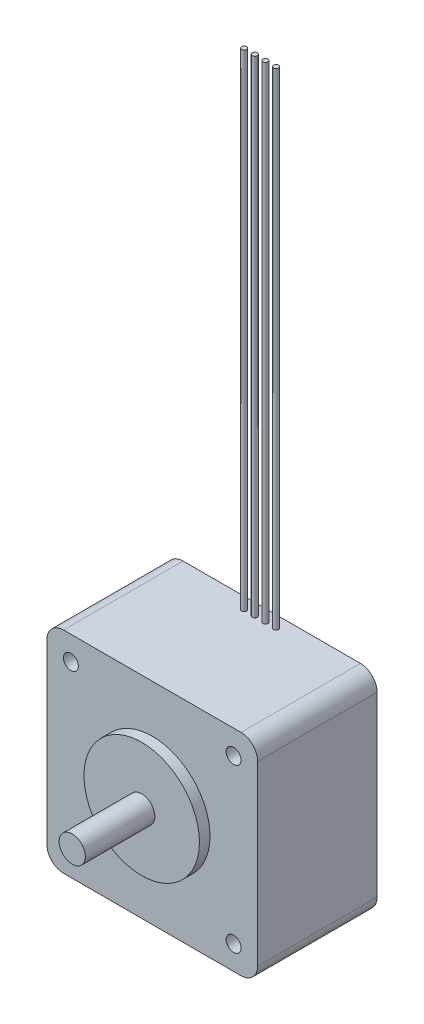
from build123d import *

# Parameters (mm, degrees)
SKETCH1_W           = 40.132
SKETCH1_H           = 40.132
BOSS_EXTRUDE1_DEPTH = 22.7584
SKETCH2_W           = 0.4826
SKETCH2_H           = 92.619583511
SKETCH3_W           = 0.4826
SKETCH3_H           = 92.619583511
SKETCH4_W           = 0.4826
SKETCH4_H           = 92.619583511
SKETCH5_W           = 0.4826
SKETCH5_H           = 92.619583511
HOLE1_D             = 2.8448
HOLE1_DEPTH         = 21.9964
HOLE2_D             = 2.8448
HOLE2_DEPTH         = 21.9964
HOLE3_D             = 2.8448
HOLE3_DEPTH         = 21.9964
HOLE4_D             = 2.8448
HOLE4_DEPTH         = 21.9964
FILLET1_R           = 3.175
FILLET2_R           = 3.175
FILLET3_R           = 3.175
FILLET4_R           = 3.175


with BuildPart() as part:
    # Sketch1 → Boss-Extrude1 (new body)
    with BuildSketch(Plane.XY.offset(22.7584)):
        Rectangle(SKETCH1_W, SKETCH1_H)
    extrude(amount=-BOSS_EXTRUDE1_DEPTH)

    # Sketch2 → Revolve1 (revolve)
    with BuildSketch(Plane(origin=(0, 0, 2.2098), x_dir=(-1, 0, 0), z_dir=(0, 0, -1))):
        with Locations((2.8067, 66.375791756)):
            Rectangle(SKETCH2_W, SKETCH2_H)
    revolve(axis=Axis((-3.048, 20.066, 2.2098), (0, 1, 0)))

    # Sketch3 → Revolve2 (revolve)
    with BuildSketch(Plane(origin=(0, 0, 2.2098), x_dir=(-1, 0, 0), z_dir=(0, 0, -1))):
        with Locations((-1.2573, 66.375791756)):
            Rectangle(SKETCH3_W, SKETCH3_H)
    revolve(axis=Axis((1.016, 20.066, 2.2098), (0, 1, 0)))

    # Sketch4 → Revolve3 (revolve)
    with BuildSketch(Plane(origin=(0, 0, 2.2098), x_dir=(-1, 0, 0), z_dir=(0, 0, -1))):
        with Locations((-3.2893, 66.375791756)):
            Rectangle(SKETCH4_W, SKETCH4_H)
    revolve(axis=Axis((3.048, 20.066, 2.2098), (0, 1, 0)))

    # Sketch5 → Revolve4 (revolve)
    with BuildSketch(Plane(origin=(0, 0, 2.2098), x_dir=(-1, 0, 0), z_dir=(0, 0, -1))):
        with Locations((0.7747, 66.375791756)):
            Rectangle(SKETCH5_W, SKETCH5_H)
    revolve(axis=Axis((-1.016, 20.066, 2.2098), (0, 1, 0)))

    # Sketch6 → Revolve5 (revolve)
    with BuildSketch(Plane(origin=(0, 0, 0), x_dir=(1, 0, 0), z_dir=(0, 1, 0))):
        Polygon((10.9982, -22.7584), (0, -22.7584), (0, -37.9984), (2.49936, -37.9984), (2.49936, -24.765), (10.9982, -24.765), align=None)
    revolve(axis=Axis((0, 0, 22.7584), (0, 0, 1)))

    # Hole1
    with Locations(Plane.XY.offset(22.7584)):
        with Locations((-15.494, 15.494)):
            Hole(HOLE1_D / 2, depth=HOLE1_DEPTH)

    # Hole2
    with Locations(Plane.XY.offset(22.7584)):
        with Locations((15.494, 15.494)):
            Hole(HOLE2_D / 2, depth=HOLE2_DEPTH)

    # Hole3
    with Locations(Plane.XY.offset(22.7584)):
        with Locations((-15.494, -15.494)):
            Hole(HOLE3_D / 2, depth=HOLE3_DEPTH)

    # Hole4
    with Locations(Plane.XY.offset(22.7584)):
        with Locations((15.494, -15.494)):
            Hole(HOLE4_D / 2, depth=HOLE4_DEPTH)

    # Fillet1
    fillet1_edges = [part.edges().sort_by_distance(p)[0] for p in [
        (20.066, -20.066, 11.3792),
    ]]
    fillet(fillet1_edges, radius=FILLET1_R)

    # Fillet2
    fillet2_edges = [part.edges().sort_by_distance(p)[0] for p in [
        (-20.066, -20.066, 11.3792),
    ]]
    fillet(fillet2_edges, radius=FILLET2_R)

    # Fillet3
    fillet3_edges = [part.edges().sort_by_distance(p)[0] for p in [
        (20.066, 20.066, 11.3792),
    ]]
    fillet(fillet3_edges, radius=FILLET3_R)

    # Fillet4
    fillet4_edges = [part.edges().sort_by_distance(p)[0] for p in [
        (-20.066, 20.066, 11.3792),
    ]]
    fillet(fillet4_edges, radius=FILLET4_R)


solid = part.part
